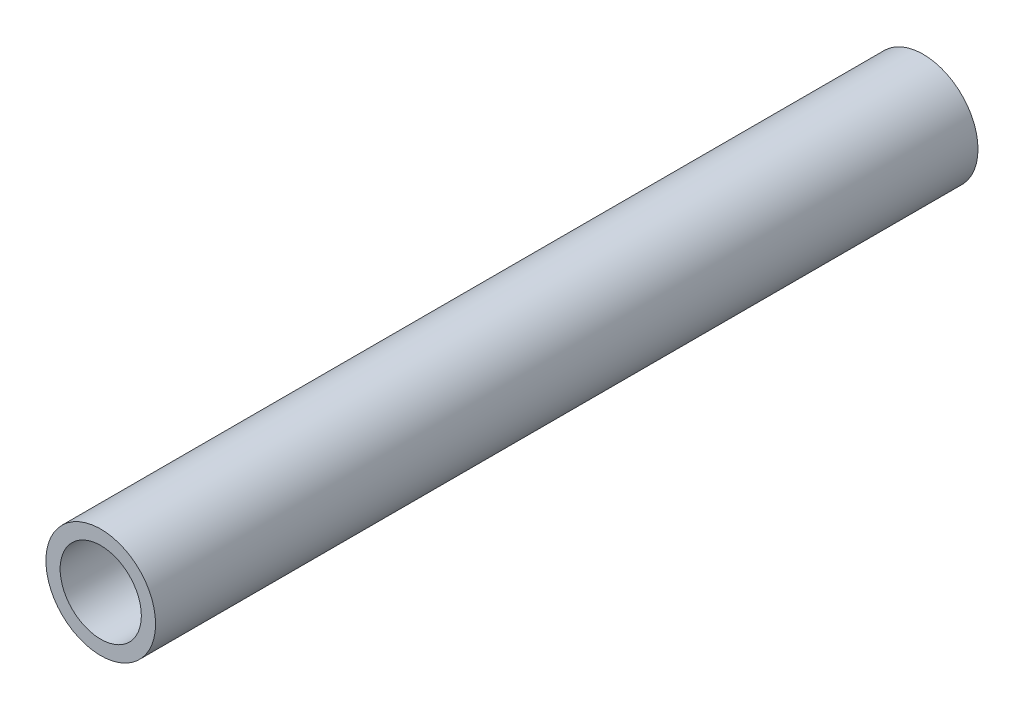
from build123d import *

# Parameters (mm, degrees)
SKETCH1_R           = 10.668
SKETCH1_R_2         = 7.8994
EXTRUDE_THIN1_DEPTH = 80


with BuildPart() as part:
    # Sketch1 → Extrude-Thin1 (new body, symmetric)
    with BuildSketch(Plane.XY):
        Circle(SKETCH1_R)
        Circle(SKETCH1_R_2, mode=Mode.SUBTRACT)
    extrude(amount=EXTRUDE_THIN1_DEPTH, both=True)


solid = part.part
